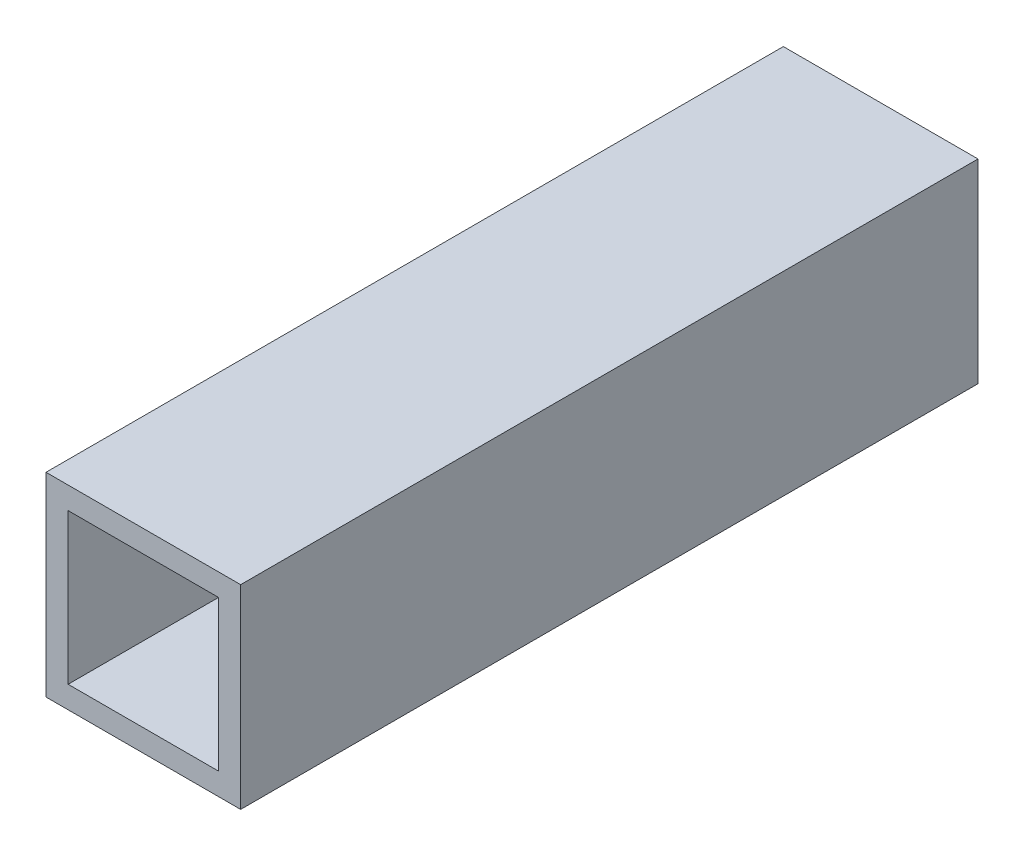
from build123d import *

# Parameters (mm, degrees)
SKETCH1_W           = 13.2
SKETCH1_H           = 13.2
SKETCH1_W_2         = 10.2
SKETCH1_H_2         = 10.2
BOSS_EXTRUDE1_DEPTH = 50


with BuildPart() as part:
    # Sketch1 → Boss-Extrude1 (new body)
    with BuildSketch(Plane.XY):
        with Locations((4.215789474, -0.268421053)):
            Rectangle(SKETCH1_W, SKETCH1_H)
        with Locations((4.215789474, -0.268421053)):
            Rectangle(SKETCH1_W_2, SKETCH1_H_2, mode=Mode.SUBTRACT)
    extrude(amount=BOSS_EXTRUDE1_DEPTH)


solid = part.part
